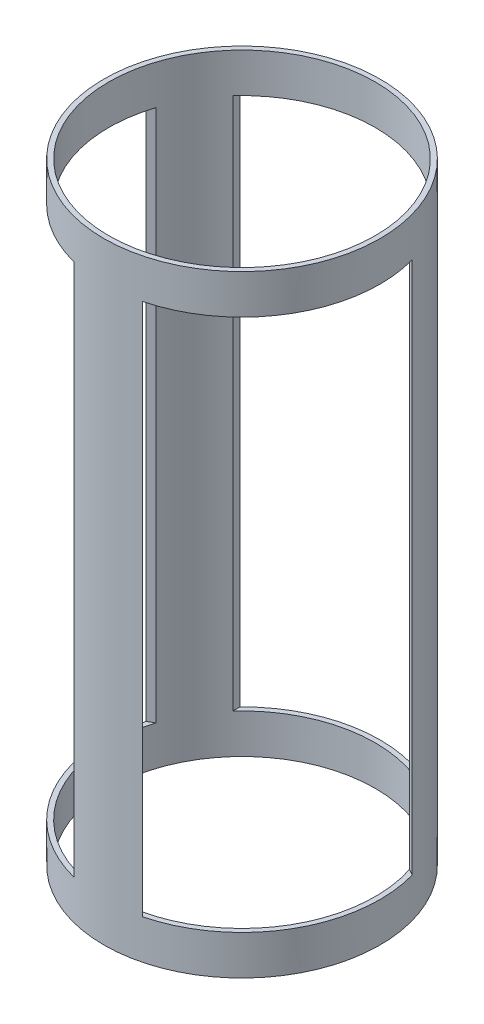
from build123d import *

# Parameters (mm, degrees)
SKETCH1_R           = 88.9
SKETCH1_R_2         = 85.725
BOSS_EXTRUDE1_DEPTH = 196.85
CUT_EXTRUDE1_START  = -88.9
SKETCH2_W           = 127
SKETCH2_H           = 342.9
CUT_EXTRUDE1_DEPTH  = 31.310716
CIRPATTERN1_COUNT   = 3


with BuildPart() as part:
    # Sketch1 → Boss-Extrude1 (new body, symmetric)
    with BuildSketch(Plane(origin=(0, 0, 0), x_dir=(1, 0, 0), z_dir=(0, 1, 0))):
        Circle(SKETCH1_R)
        Circle(SKETCH1_R_2, mode=Mode.SUBTRACT)
    extrude(amount=BOSS_EXTRUDE1_DEPTH, both=True)

    # Sketch2 → Cut-Extrude1 (cut)
    with BuildSketch(Plane.XY.offset(CUT_EXTRUDE1_START)):
        Rectangle(SKETCH2_W, SKETCH2_H)
    cut_extrude1 = extrude(amount=CUT_EXTRUDE1_DEPTH, mode=Mode.SUBTRACT)

    # CirPattern1: Cut-Extrude1 ×3 about axis
    cirpattern1_axis = Axis((0, 0, 0), (0, 1, 0))
    for i in range(1, CIRPATTERN1_COUNT):
        add(cut_extrude1.rotate(cirpattern1_axis, i * 360 / CIRPATTERN1_COUNT), mode=Mode.SUBTRACT)


solid = part.part
